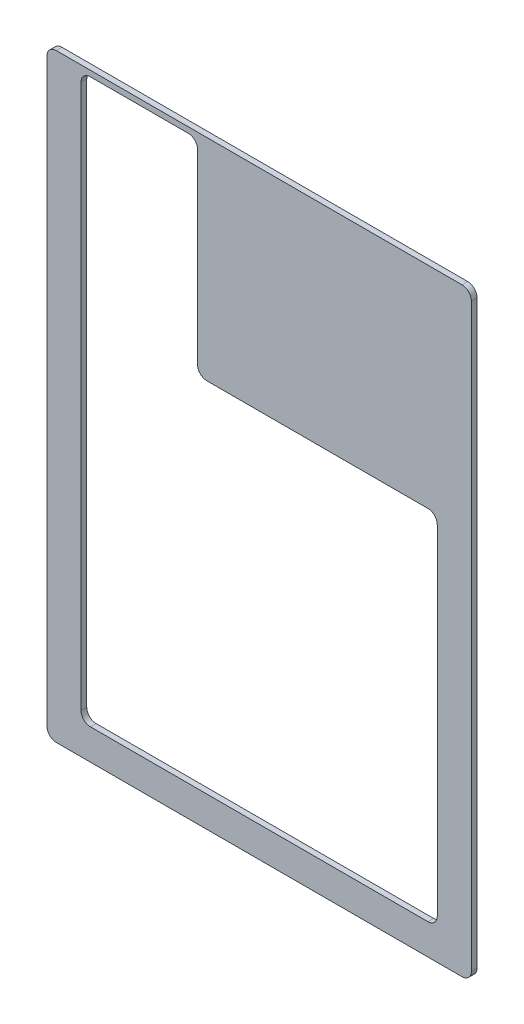
from build123d import *

# Parameters (mm, degrees)
SKETCH1_W           = 323.85
SKETCH1_H           = 457.2
BOSS_EXTRUDE1_DEPTH = 4.3434
SKETCH2_W           = 271.78
SKETCH2_H           = 273.05
CUT_EXTRUDE1_DEPTH  = 5.3434
FILLET1_R           = 7.14375
SKETCH4_W           = 88.9
SKETCH4_H           = 184.911324328
CUT_EXTRUDE3_DEPTH  = 5.3434
FILLET2_R           = 7.14375


with BuildPart() as part:
    # Sketch1 → Boss-Extrude1 (new body)
    with BuildSketch(Plane.XY):
        Rectangle(SKETCH1_W, SKETCH1_H)
    extrude(amount=BOSS_EXTRUDE1_DEPTH)

    # Sketch2 → Cut-Extrude1 (cut, through all)
    with BuildSketch(Plane.XY.offset(4.3434)):
        with Locations((0, -68.707)):
            Rectangle(SKETCH2_W, SKETCH2_H)
    extrude(amount=-CUT_EXTRUDE1_DEPTH, mode=Mode.SUBTRACT)

    # Fillet1
    fillet1_edges = [part.edges().sort_by_distance(p)[0] for p in [
        (135.89, 67.818, 2.1717),
        (135.89, -205.232, 2.1717),
        (-135.89, -205.232, 2.1717),
        (-135.89, 67.818, 2.1717),
        (161.925, -228.6, 2.1717),
        (-161.925, -228.6, 2.1717),
        (-161.925, 228.6, 2.1717),
        (161.925, 228.6, 2.1717),
    ]]
    fillet(fillet1_edges, radius=FILLET1_R)

    # Sketch4 → Cut-Extrude3 (cut, through all)
    with BuildSketch(Plane.XY.offset(4.3434)):
        with Locations((-91.44, 131.800937836)):
            Rectangle(SKETCH4_W, SKETCH4_H)
    extrude(amount=-CUT_EXTRUDE3_DEPTH, mode=Mode.SUBTRACT)

    # Fillet2
    fillet2_edges = [part.edges().sort_by_distance(p)[0] for p in [
        (-46.99, 67.818, 2.1717),
        (-46.99, 224.2566, 2.1717),
        (-135.89, 224.2566, 2.1717),
    ]]
    fillet(fillet2_edges, radius=FILLET2_R)


solid = part.part
